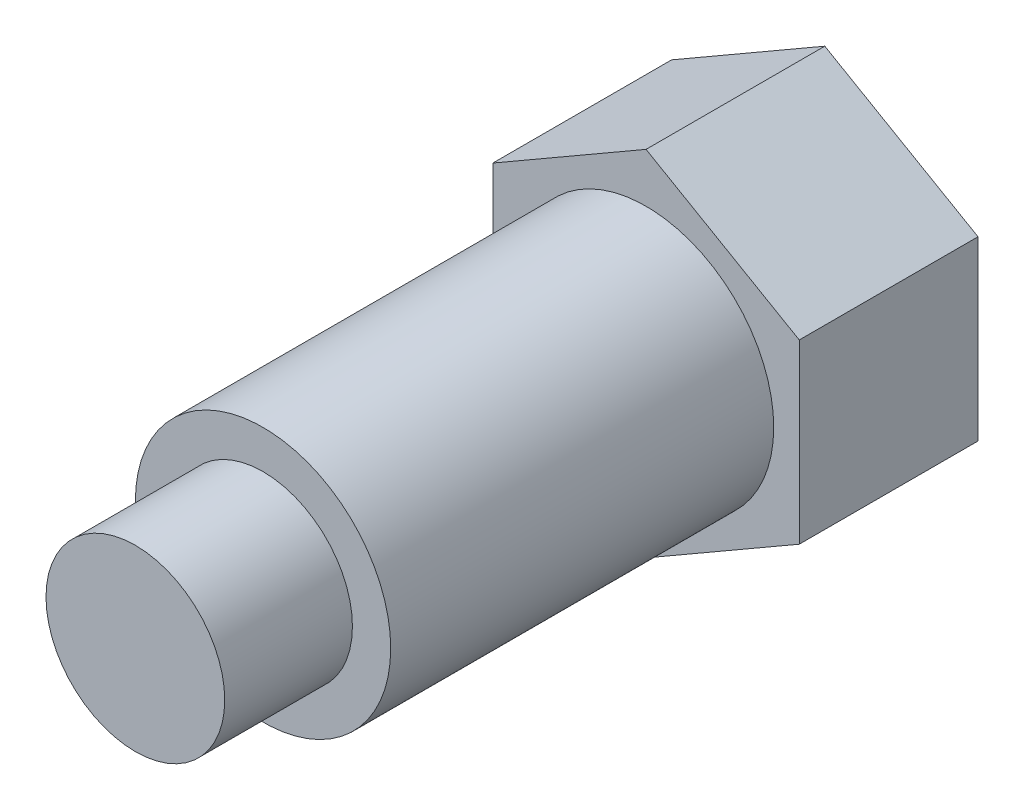
from build123d import *

# Parameters (mm, degrees)
BOSS_EXTRUDE1_DEPTH = 7


with BuildPart() as part:
    # Sketch1 → Base-Revolve (revolve)
    with BuildSketch(Plane(origin=(0, 0, 0), x_dir=(1, 0, 0), z_dir=(0, 1, 0))):
        Polygon((0, 0), (0, -20), (3.5, -20), (3.5, -15), (5, -15), (5, 0), align=None)
    revolve(axis=Axis((0, 0, -1.187299328), (0, 0, 1)))

    # Sketch2 → Boss-Extrude1 (add)
    with BuildSketch(Plane(origin=(0, 0, 0), x_dir=(-1, 0, 0), z_dir=(0, 0, -1))):
        Polygon((6, -3.464101615), (6, 3.464101615), (0, 6.92820323), (-6, 3.464101615), (-6, -3.464101615), (0, -6.92820323), align=None)
    extrude(amount=BOSS_EXTRUDE1_DEPTH)


solid = part.part
